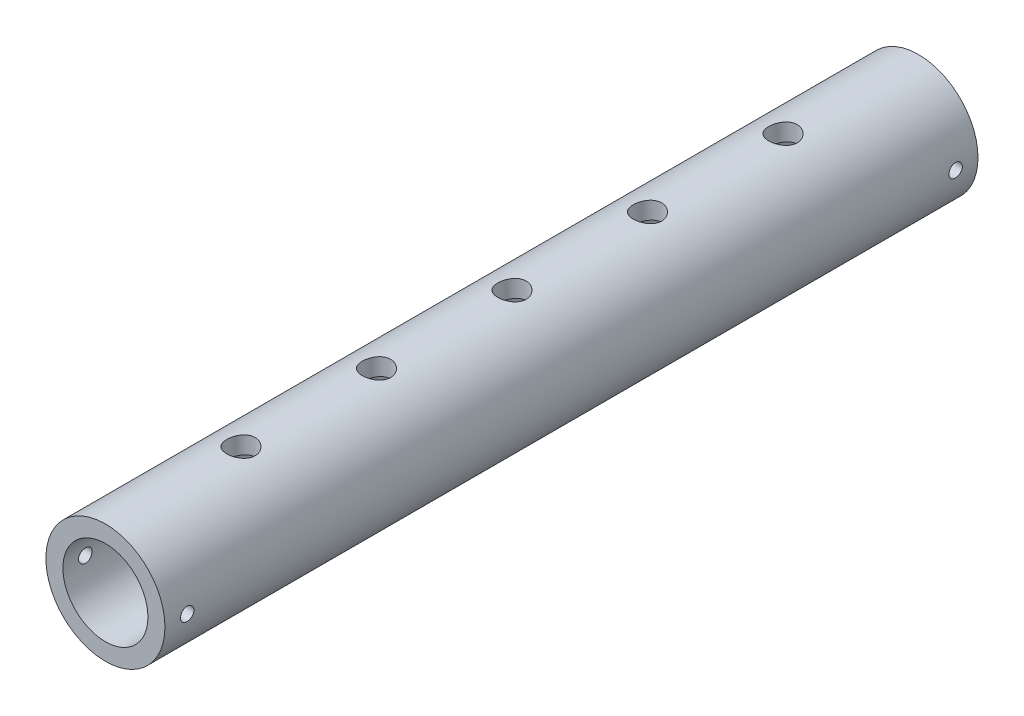
from build123d import *

# Parameters (mm, degrees)
SKETCH2_R               = 13.335
SKETCH2_R_2             = 9.525
BOSS_EXTRUDE1_DEPTH     = 182.118
SKETCH3_R               = 3.175
CUT_EXTRUDE1_DEPTH      = 14.335
CUT_EXTRUDE1_DEPTH_BACK = 14.335
SKETCH4_R               = 1.5
CUT_EXTRUDE2_DEPTH      = 14.3350001
CUT_EXTRUDE2_DEPTH_BACK = 14.3350001


with BuildPart() as part:
    # Sketch2 → Boss-Extrude1 (new body)
    with BuildSketch(Plane.XY):
        Circle(SKETCH2_R)
        Circle(SKETCH2_R_2, mode=Mode.SUBTRACT)
    extrude(amount=BOSS_EXTRUDE1_DEPTH)

    # Sketch3 → Cut-Extrude1 (cut, two sides)
    with BuildSketch(Plane(origin=(0, 0, 0), x_dir=(1, 0, 0), z_dir=(0, 1, 0))) as cut_extrude1_sk:
        with BuildLine():
            ThreePointArc((0, -148.59), (-3.175, -151.765), (0, -154.94))
            Line((0, -154.94), (0, -148.59))
        make_face()
        with BuildLine():
            Line((0, -148.59), (0, -154.94))
            ThreePointArc((0, -154.94), (2.24506403, -154.01006403), (3.175, -151.765))
            ThreePointArc((3.175, -151.765), (2.24506403, -149.51993597), (0, -148.59))
        make_face()
        with Locations((0, -121.412)):
            Circle(SKETCH3_R)
        with Locations((0, -91.059)):
            Circle(SKETCH3_R)
        with Locations((0, -60.706)):
            Circle(SKETCH3_R)
        with Locations((0, -30.353)):
            Circle(SKETCH3_R)
    extrude(amount=CUT_EXTRUDE1_DEPTH, mode=Mode.SUBTRACT)
    extrude(cut_extrude1_sk.sketch, amount=-CUT_EXTRUDE1_DEPTH_BACK, mode=Mode.SUBTRACT)

    # Sketch4 → Cut-Extrude2 (cut, two sides)
    with BuildSketch(Plane(origin=(0, 0, 0), x_dir=(0, 0, -1), z_dir=(1, 0, 0))) as cut_extrude2_sk:
        with Locations((-177.118, 0)):
            Circle(SKETCH4_R)
        with Locations((-5, 0)):
            Circle(SKETCH4_R)
    extrude(amount=CUT_EXTRUDE2_DEPTH, mode=Mode.SUBTRACT)
    extrude(cut_extrude2_sk.sketch, amount=-CUT_EXTRUDE2_DEPTH_BACK, mode=Mode.SUBTRACT)


solid = part.part
